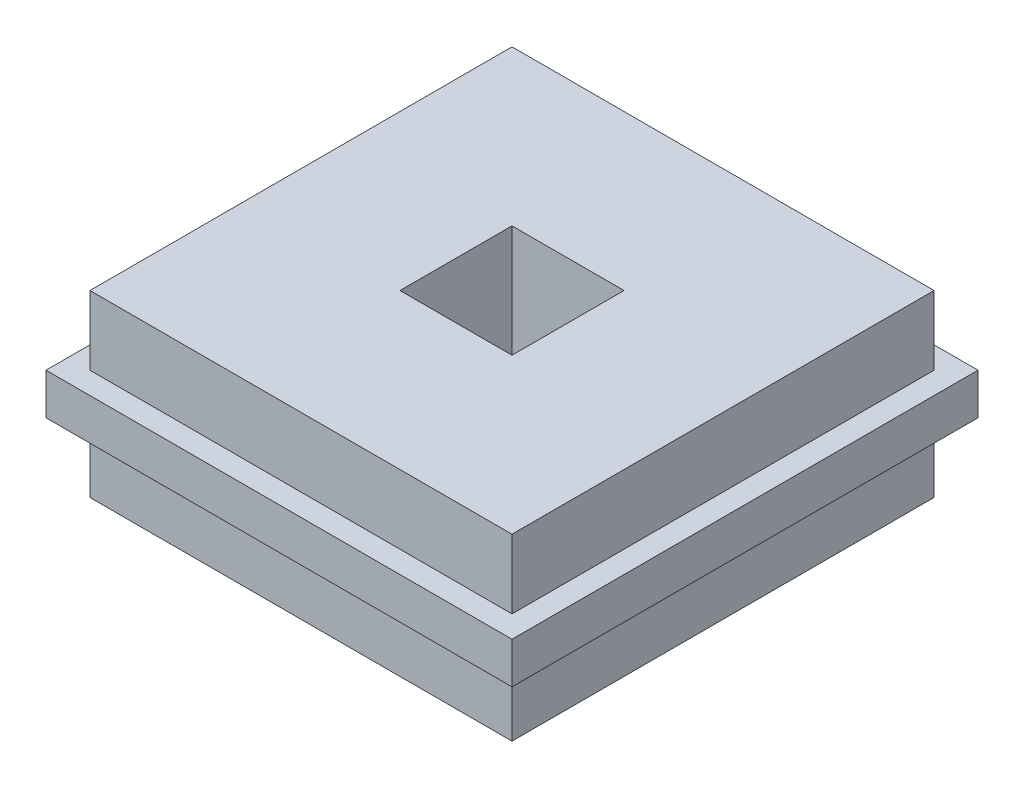
from build123d import *

# Parameters (mm, degrees)
SKETCH1_W           = 29.9085
SKETCH1_H           = 29.9085
BOSS_EXTRUDE1_DEPTH = 6.35
SKETCH2_W           = 33.02
SKETCH2_H           = 33.02
BOSS_EXTRUDE2_DEPTH = 1.4605
SKETCH4_W           = 7.9375
SKETCH4_H           = 7.9375
CUT_EXTRUDE2_DEPTH  = 13.7


with BuildPart() as part:
    # Sketch1 → Boss-Extrude1 (new body, symmetric)
    with BuildSketch(Plane(origin=(0, 0, 0), x_dir=(1, 0, 0), z_dir=(0, 1, 0))):
        Rectangle(SKETCH1_W, SKETCH1_H)
    extrude(amount=BOSS_EXTRUDE1_DEPTH, both=True)

    # Sketch2 → Boss-Extrude2 (add, symmetric)
    with BuildSketch(Plane(origin=(0, 0, 0), x_dir=(1, 0, 0), z_dir=(0, 1, 0))):
        Rectangle(SKETCH2_W, SKETCH2_H)
    extrude(amount=BOSS_EXTRUDE2_DEPTH, both=True)

    # Sketch4 → Cut-Extrude2 (cut, through all)
    with BuildSketch(Plane(origin=(0, 6.35, 0), x_dir=(1, 0, 0), z_dir=(0, 1, 0))):
        Rectangle(SKETCH4_W, SKETCH4_H)
    extrude(amount=-CUT_EXTRUDE2_DEPTH, mode=Mode.SUBTRACT)


solid = part.part
